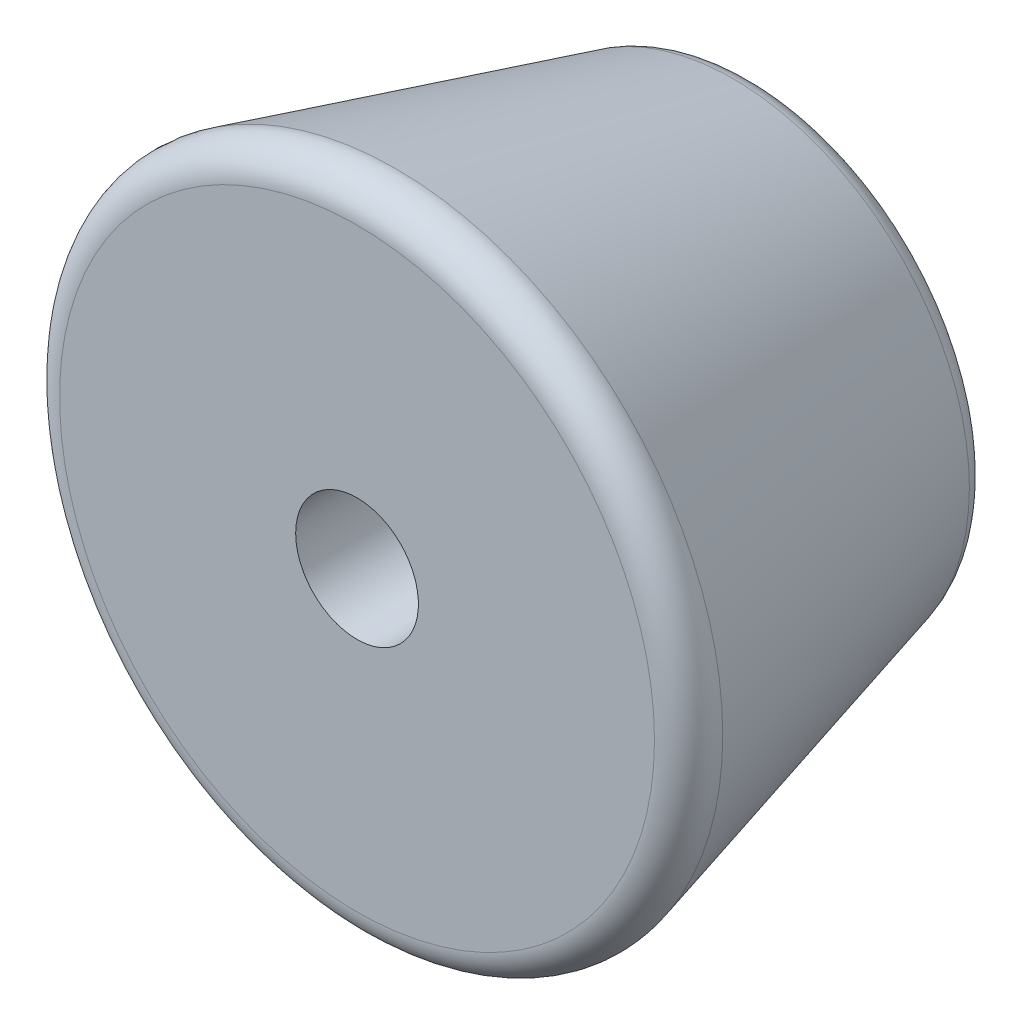
from build123d import *

# Parameters (mm, degrees)
SKETCH2_R          = 5
CUT_EXTRUDE1_DEPTH = 7
SKETCH3_R          = 2
CUT_EXTRUDE2_DEPTH = 7
FILLET1_R          = 1


with BuildPart() as part:
    # Sketch1 → Revolve1 (revolve)
    with BuildSketch(Plane(origin=(0, 0, 0), x_dir=(1, 0, 0), z_dir=(0, 1, 0))):
        Polygon((0, 0), (0, 13), (7.5, 13), (11, 0), align=None)
    revolve(axis=Axis((0, 0, 0), (0, 0, -1)))

    # Sketch2 → Cut-Extrude1 (cut)
    with BuildSketch(Plane(origin=(0, 0, -13), x_dir=(-1, 0, 0), z_dir=(0, 0, -1))):
        Circle(SKETCH2_R)
    extrude(amount=-CUT_EXTRUDE1_DEPTH, mode=Mode.SUBTRACT)

    # Sketch3 → Cut-Extrude2 (cut, through all)
    with BuildSketch(Plane(origin=(0, 0, -6), x_dir=(-1, 0, 0), z_dir=(0, 0, -1))):
        Circle(SKETCH3_R)
    extrude(amount=-CUT_EXTRUDE2_DEPTH, mode=Mode.SUBTRACT)

    # Fillet1
    fillet1_edges = [part.edges().sort_by_distance(p)[0] for p in [
        (5, 0, -13),
        (-11, 0, 0),
        (-7.5, 0, -13),
    ]]
    fillet(fillet1_edges, radius=FILLET1_R)


solid = part.part
